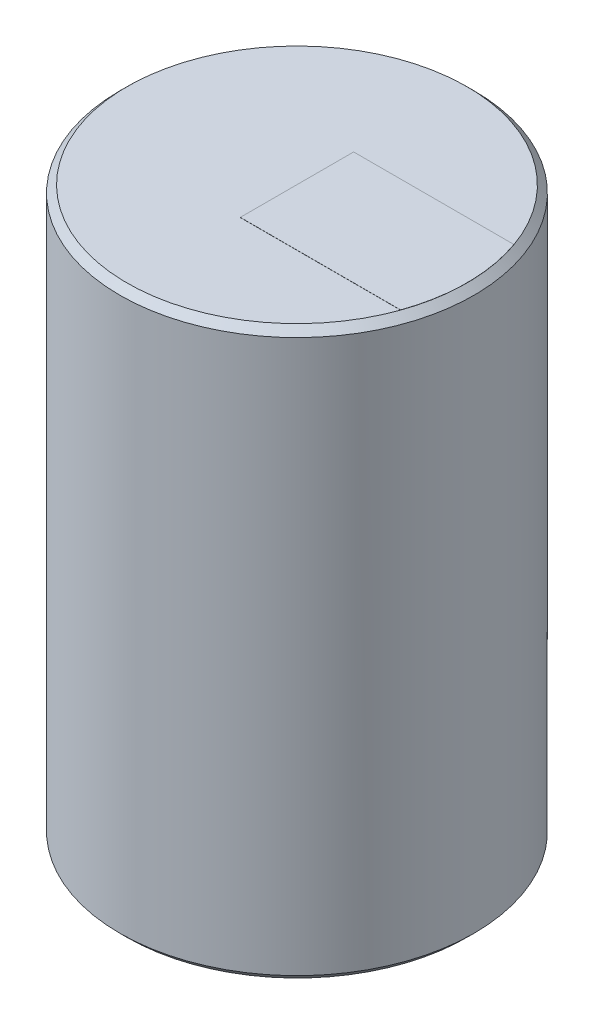
from build123d import *

# Parameters (mm, degrees)
SKETCH1_R           = 12.5
BOSS_EXTRUDE1_DEPTH = 40
CHAMFER1_SIZE       = 0.5
BOSS_EXTRUDE2_DEPTH = 0.01


with BuildPart() as part:
    # Sketch1 → Boss-Extrude1 (new body)
    with BuildSketch(Plane(origin=(0, 0, 0), x_dir=(1, 0, 0), z_dir=(0, 1, 0))):
        Circle(SKETCH1_R)
    extrude(amount=BOSS_EXTRUDE1_DEPTH)

    # Chamfer1
    chamfer1_edges = [part.edges().sort_by_distance(p)[0] for p in [
        (-12.5, 0, 0),
        (-12.5, 40, 0),
    ]]
    chamfer(chamfer1_edges, length=CHAMFER1_SIZE)

    # Sketch2 → Boss-Extrude2 (add)
    with BuildSketch(Plane(origin=(0, 40, 0), x_dir=(1, 0, 0), z_dir=(0, 1, 0))):
        with BuildLine():
            Line((11.313708499, 4), (0, 4))
            Line((0, 4), (0, -4))
            Line((0, -4), (11.313708499, -4))
            ThreePointArc((11.313708499, -4), (12, 0), (11.313708499, 4))
        make_face()
    extrude(amount=BOSS_EXTRUDE2_DEPTH)


solid = part.part
